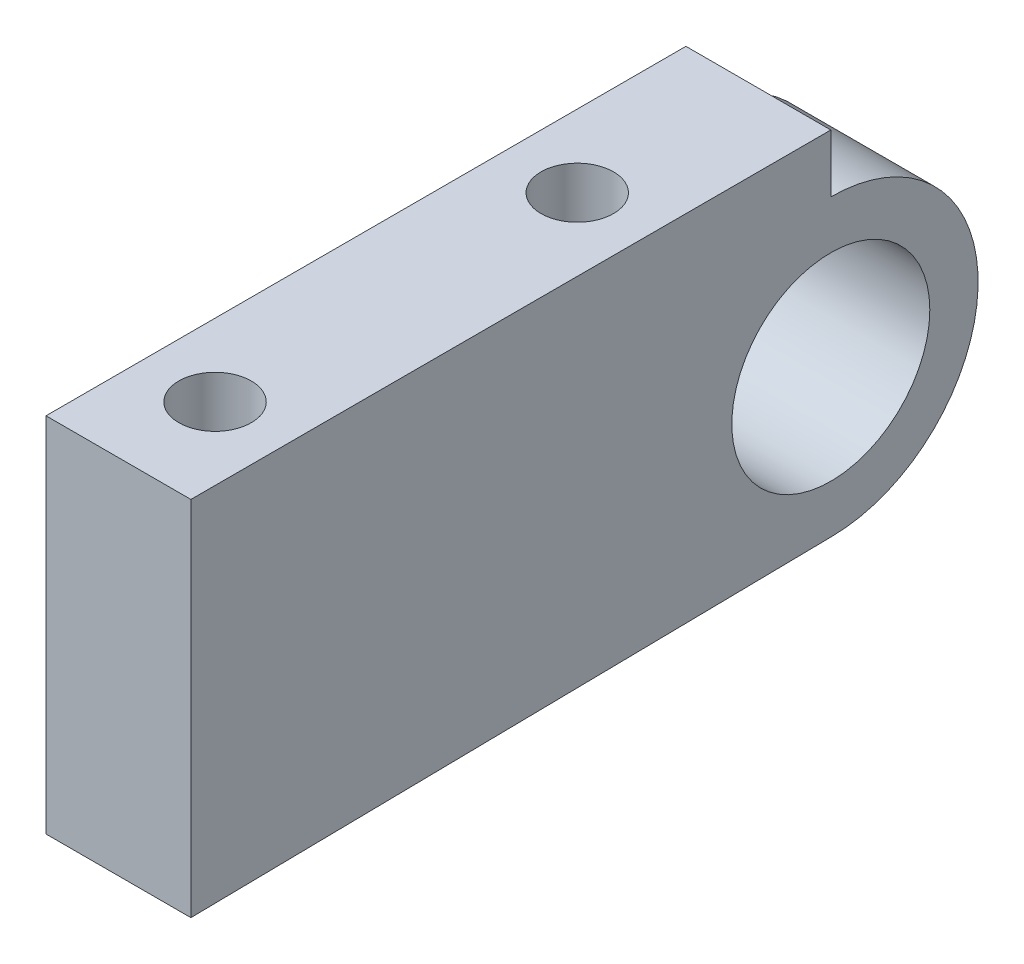
from build123d import *

# Parameters (mm, degrees)
SKETCH_1_W          = 35
SKETCH_1_H          = 15
EXTRUDE_1_DEPTH     = 6
SKETCH_2_R          = 1.5
CUT_EXTRUDE_1_DEPTH = 16
SKETCH_3_R          = 4.1
CUT_EXTRUDE_2_DEPTH = 7
CUT_EXTRUDE_3_DEPTH = 7


with BuildPart() as part:
    # 草图1 → 凸台-拉伸1 (new body)
    with BuildSketch(Plane(origin=(0, 0, 0), x_dir=(0, 0, -1), z_dir=(1, 0, 0))):
        Rectangle(SKETCH_1_W, SKETCH_1_H)
    extrude(amount=EXTRUDE_1_DEPTH)

    # 草图2 → 切除-拉伸1 (cut, through all)
    with BuildSketch(Plane(origin=(0, 7.5, 0), x_dir=(1, 0, 0), z_dir=(0, 1, 0))):
        with Locations((3, -13.5)):
            Circle(SKETCH_2_R)
        with Locations((3, 1.5)):
            Circle(SKETCH_2_R)
    extrude(amount=-CUT_EXTRUDE_1_DEPTH, mode=Mode.SUBTRACT)

    # 草图3 → 切除-拉伸2 (cut, through all)
    with BuildSketch(Plane(origin=(6, 0, 0), x_dir=(0, 0, -1), z_dir=(1, 0, 0))):
        with Locations((9, -1)):
            Circle(SKETCH_3_R)
    extrude(amount=-CUT_EXTRUDE_2_DEPTH, mode=Mode.SUBTRACT)

    # 草图4 → 切除-拉伸3 (cut, through all)
    with BuildSketch(Plane(origin=(6, 0, 0), x_dir=(0, 0, -1), z_dir=(1, 0, 0))):
        with BuildLine():
            Line((9, 5.1), (9, 7.5))
            Line((9, 7.5), (17.5, 7.5))
            Line((17.5, 7.5), (17.5, -7.5))
            Line((17.5, -7.5), (-17.5, -7.5))
            Line((-17.5, -7.5), (9.091905641, -7.099307613))
            ThreePointArc((9.091905641, -7.099307613), (15.099826901, -0.954045876), (9, 5.1))
        make_face()
    extrude(amount=-CUT_EXTRUDE_3_DEPTH, mode=Mode.SUBTRACT)


solid = part.part
